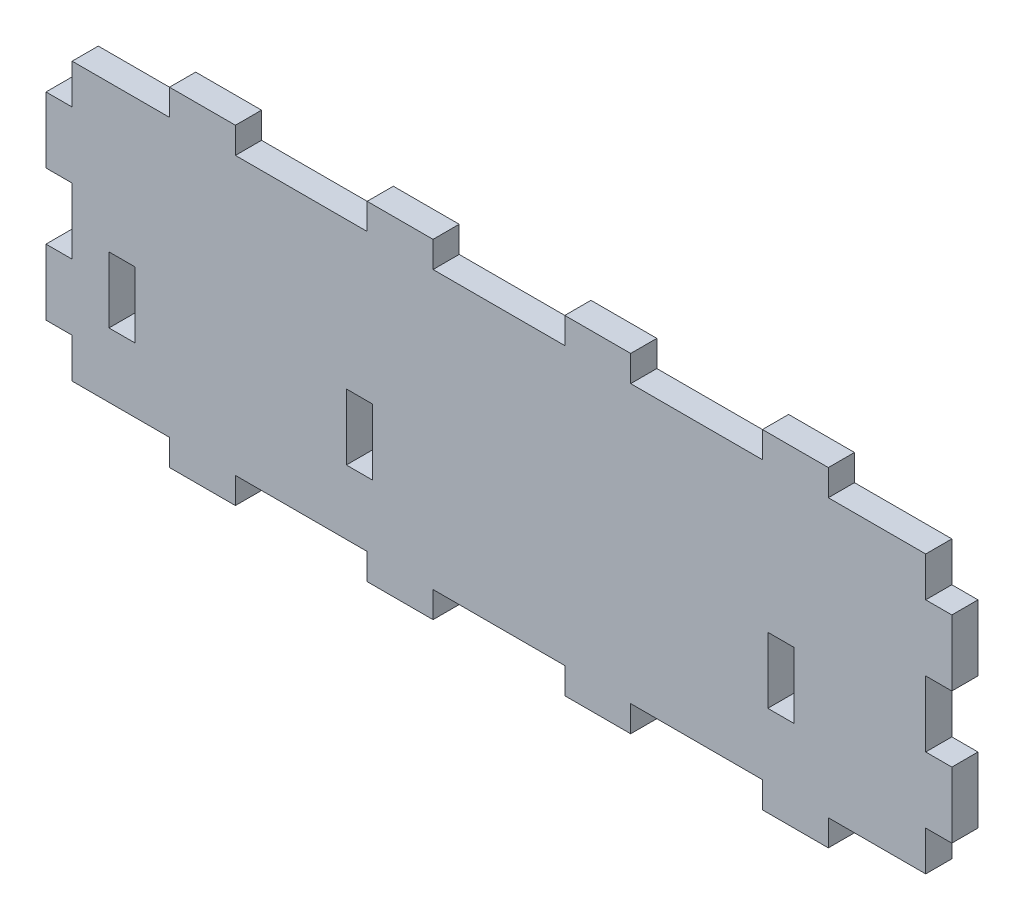
from build123d import *

# Parameters (mm, degrees)
SKETCH1_W           = 110
SKETCH1_H           = 40
BOSS_EXTRUDE1_DEPTH = 3.175
CUT_EXTRUDE5_REACH  = 5.175
SKETCH6_W           = 15
SKETCH6_H           = 3.175
SKETCH6_W_2         = 16
CUT_EXTRUDE6_REACH  = 5.175
SKETCH7_W           = 3.175
SKETCH7_H           = 4.825
SKETCH7_H_2         = 8
CUT_EXTRUDE7_REACH  = 5.175
SKETCH8_W           = 3.175
SKETCH8_H           = 8


with BuildPart() as part:
    # Sketch1 → Boss-Extrude1 (new body)
    with BuildSketch(Plane.XY):
        with Locations((55, -20)):
            Rectangle(SKETCH1_W, SKETCH1_H)
    extrude(amount=BOSS_EXTRUDE1_DEPTH)

    # Sketch6 → Cut-Extrude5 (cut, up to next)
    with BuildSketch(Plane(origin=(0, 0, 0), x_dir=(-1, 0, 0), z_dir=(0, 0, -1)), mode=Mode.PRIVATE) as cut_extrude5_sk1:
        with Locations((-102.5, -38.4125)):
            Rectangle(SKETCH6_W, SKETCH6_H)
    cut_extrude5_tool1 = extrude(cut_extrude5_sk1.sketch, amount=-CUT_EXTRUDE5_REACH, mode=Mode.PRIVATE) & part.part
    add(cut_extrude5_tool1.solids().sort_by_distance((102.5, -38.4125, 0))[0], mode=Mode.SUBTRACT)
    # Sketch6 → Cut-Extrude5 (cut, up to next)
    with BuildSketch(Plane(origin=(0, 0, 0), x_dir=(-1, 0, 0), z_dir=(0, 0, -1)), mode=Mode.PRIVATE) as cut_extrude5_sk2:
        with Locations((-55, -38.4125)):
            Rectangle(SKETCH6_W_2, SKETCH6_H)
    cut_extrude5_tool2 = extrude(cut_extrude5_sk2.sketch, amount=-CUT_EXTRUDE5_REACH, mode=Mode.PRIVATE) & part.part
    add(cut_extrude5_tool2.solids().sort_by_distance((55, -38.4125, 0))[0], mode=Mode.SUBTRACT)
    # Sketch6 → Cut-Extrude5 (cut, up to next)
    with BuildSketch(Plane(origin=(0, 0, 0), x_dir=(-1, 0, 0), z_dir=(0, 0, -1)), mode=Mode.PRIVATE) as cut_extrude5_sk3:
        with Locations((-31, -38.4125)):
            Rectangle(SKETCH6_W_2, SKETCH6_H)
    cut_extrude5_tool3 = extrude(cut_extrude5_sk3.sketch, amount=-CUT_EXTRUDE5_REACH, mode=Mode.PRIVATE) & part.part
    add(cut_extrude5_tool3.solids().sort_by_distance((31, -38.4125, 0))[0], mode=Mode.SUBTRACT)
    # Sketch6 → Cut-Extrude5 (cut, up to next)
    with BuildSketch(Plane(origin=(0, 0, 0), x_dir=(-1, 0, 0), z_dir=(0, 0, -1)), mode=Mode.PRIVATE) as cut_extrude5_sk4:
        with Locations((-7.5, -38.4125)):
            Rectangle(SKETCH6_W, SKETCH6_H)
    cut_extrude5_tool4 = extrude(cut_extrude5_sk4.sketch, amount=-CUT_EXTRUDE5_REACH, mode=Mode.PRIVATE) & part.part
    add(cut_extrude5_tool4.solids().sort_by_distance((7.5, -38.4125, 0))[0], mode=Mode.SUBTRACT)
    # Sketch6 → Cut-Extrude5 (cut, up to next)
    with BuildSketch(Plane(origin=(0, 0, 0), x_dir=(-1, 0, 0), z_dir=(0, 0, -1)), mode=Mode.PRIVATE) as cut_extrude5_sk5:
        with Locations((-79, -38.4125)):
            Rectangle(SKETCH6_W_2, SKETCH6_H)
    cut_extrude5_tool5 = extrude(cut_extrude5_sk5.sketch, amount=-CUT_EXTRUDE5_REACH, mode=Mode.PRIVATE) & part.part
    add(cut_extrude5_tool5.solids().sort_by_distance((79, -38.4125, 0))[0], mode=Mode.SUBTRACT)
    # Sketch6 → Cut-Extrude5 (cut, up to next)
    with BuildSketch(Plane(origin=(0, 0, 0), x_dir=(-1, 0, 0), z_dir=(0, 0, -1)), mode=Mode.PRIVATE) as cut_extrude5_sk6:
        with Locations((-55, -1.5875)):
            Rectangle(SKETCH6_W_2, SKETCH6_H)
    cut_extrude5_tool6 = extrude(cut_extrude5_sk6.sketch, amount=-CUT_EXTRUDE5_REACH, mode=Mode.PRIVATE) & part.part
    add(cut_extrude5_tool6.solids().sort_by_distance((55, -1.5875, 0))[0], mode=Mode.SUBTRACT)
    # Sketch6 → Cut-Extrude5 (cut, up to next)
    with BuildSketch(Plane(origin=(0, 0, 0), x_dir=(-1, 0, 0), z_dir=(0, 0, -1)), mode=Mode.PRIVATE) as cut_extrude5_sk7:
        with Locations((-79, -1.5875)):
            Rectangle(SKETCH6_W_2, SKETCH6_H)
    cut_extrude5_tool7 = extrude(cut_extrude5_sk7.sketch, amount=-CUT_EXTRUDE5_REACH, mode=Mode.PRIVATE) & part.part
    add(cut_extrude5_tool7.solids().sort_by_distance((79, -1.5875, 0))[0], mode=Mode.SUBTRACT)
    # Sketch6 → Cut-Extrude5 (cut, up to next)
    with BuildSketch(Plane(origin=(0, 0, 0), x_dir=(-1, 0, 0), z_dir=(0, 0, -1)), mode=Mode.PRIVATE) as cut_extrude5_sk8:
        with Locations((-102.5, -1.5875)):
            Rectangle(SKETCH6_W, SKETCH6_H)
    cut_extrude5_tool8 = extrude(cut_extrude5_sk8.sketch, amount=-CUT_EXTRUDE5_REACH, mode=Mode.PRIVATE) & part.part
    add(cut_extrude5_tool8.solids().sort_by_distance((102.5, -1.5875, 0))[0], mode=Mode.SUBTRACT)
    # Sketch6 → Cut-Extrude5 (cut, up to next)
    with BuildSketch(Plane(origin=(0, 0, 0), x_dir=(-1, 0, 0), z_dir=(0, 0, -1)), mode=Mode.PRIVATE) as cut_extrude5_sk9:
        with Locations((-7.5, -1.5875)):
            Rectangle(SKETCH6_W, SKETCH6_H)
    cut_extrude5_tool9 = extrude(cut_extrude5_sk9.sketch, amount=-CUT_EXTRUDE5_REACH, mode=Mode.PRIVATE) & part.part
    add(cut_extrude5_tool9.solids().sort_by_distance((7.5, -1.5875, 0))[0], mode=Mode.SUBTRACT)
    # Sketch6 → Cut-Extrude5 (cut, up to next)
    with BuildSketch(Plane(origin=(0, 0, 0), x_dir=(-1, 0, 0), z_dir=(0, 0, -1)), mode=Mode.PRIVATE) as cut_extrude5_sk10:
        with Locations((-31, -1.5875)):
            Rectangle(SKETCH6_W_2, SKETCH6_H)
    cut_extrude5_tool10 = extrude(cut_extrude5_sk10.sketch, amount=-CUT_EXTRUDE5_REACH, mode=Mode.PRIVATE) & part.part
    add(cut_extrude5_tool10.solids().sort_by_distance((31, -1.5875, 0))[0], mode=Mode.SUBTRACT)

    # Sketch7 → Cut-Extrude6 (cut, up to next)
    with BuildSketch(Plane(origin=(0, 0, 0), x_dir=(-1, 0, 0), z_dir=(0, 0, -1)), mode=Mode.PRIVATE) as cut_extrude6_sk1:
        with Locations((-108.4125, -34.4125)):
            Rectangle(SKETCH7_W, SKETCH7_H)
    cut_extrude6_tool1 = extrude(cut_extrude6_sk1.sketch, amount=-CUT_EXTRUDE6_REACH, mode=Mode.PRIVATE) & part.part
    add(cut_extrude6_tool1.solids().sort_by_distance((108.4125, -34.4125, 0))[0], mode=Mode.SUBTRACT)
    # Sketch7 → Cut-Extrude6 (cut, up to next)
    with BuildSketch(Plane(origin=(0, 0, 0), x_dir=(-1, 0, 0), z_dir=(0, 0, -1)), mode=Mode.PRIVATE) as cut_extrude6_sk2:
        with Locations((-108.4125, -20)):
            Rectangle(SKETCH7_W, SKETCH7_H_2)
    cut_extrude6_tool2 = extrude(cut_extrude6_sk2.sketch, amount=-CUT_EXTRUDE6_REACH, mode=Mode.PRIVATE) & part.part
    add(cut_extrude6_tool2.solids().sort_by_distance((108.4125, -20, 0))[0], mode=Mode.SUBTRACT)
    # Sketch7 → Cut-Extrude6 (cut, up to next)
    with BuildSketch(Plane(origin=(0, 0, 0), x_dir=(-1, 0, 0), z_dir=(0, 0, -1)), mode=Mode.PRIVATE) as cut_extrude6_sk3:
        with Locations((-108.4125, -5.5875)):
            Rectangle(SKETCH7_W, SKETCH7_H)
    cut_extrude6_tool3 = extrude(cut_extrude6_sk3.sketch, amount=-CUT_EXTRUDE6_REACH, mode=Mode.PRIVATE) & part.part
    add(cut_extrude6_tool3.solids().sort_by_distance((108.4125, -5.5875, 0))[0], mode=Mode.SUBTRACT)
    # Sketch7 → Cut-Extrude6 (cut, up to next)
    with BuildSketch(Plane(origin=(0, 0, 0), x_dir=(-1, 0, 0), z_dir=(0, 0, -1)), mode=Mode.PRIVATE) as cut_extrude6_sk4:
        with Locations((-1.5875, -20)):
            Rectangle(SKETCH7_W, SKETCH7_H_2)
    cut_extrude6_tool4 = extrude(cut_extrude6_sk4.sketch, amount=-CUT_EXTRUDE6_REACH, mode=Mode.PRIVATE) & part.part
    add(cut_extrude6_tool4.solids().sort_by_distance((1.5875, -20, 0))[0], mode=Mode.SUBTRACT)
    # Sketch7 → Cut-Extrude6 (cut, up to next)
    with BuildSketch(Plane(origin=(0, 0, 0), x_dir=(-1, 0, 0), z_dir=(0, 0, -1)), mode=Mode.PRIVATE) as cut_extrude6_sk5:
        with Locations((-1.5875, -34.4125)):
            Rectangle(SKETCH7_W, SKETCH7_H)
    cut_extrude6_tool5 = extrude(cut_extrude6_sk5.sketch, amount=-CUT_EXTRUDE6_REACH, mode=Mode.PRIVATE) & part.part
    add(cut_extrude6_tool5.solids().sort_by_distance((1.5875, -34.4125, 0))[0], mode=Mode.SUBTRACT)
    # Sketch7 → Cut-Extrude6 (cut, up to next)
    with BuildSketch(Plane(origin=(0, 0, 0), x_dir=(-1, 0, 0), z_dir=(0, 0, -1)), mode=Mode.PRIVATE) as cut_extrude6_sk6:
        with Locations((-1.5875, -5.5875)):
            Rectangle(SKETCH7_W, SKETCH7_H)
    cut_extrude6_tool6 = extrude(cut_extrude6_sk6.sketch, amount=-CUT_EXTRUDE6_REACH, mode=Mode.PRIVATE) & part.part
    add(cut_extrude6_tool6.solids().sort_by_distance((1.5875, -5.5875, 0))[0], mode=Mode.SUBTRACT)

    # Sketch8 → Cut-Extrude7 (cut, up to next)
    with BuildSketch(Plane(origin=(0, 0, 0), x_dir=(-1, 0, 0), z_dir=(0, 0, -1)), mode=Mode.PRIVATE) as cut_extrude7_sk1:
        with Locations((-38.0625, -24.995)):
            Rectangle(SKETCH8_W, SKETCH8_H)
    cut_extrude7_tool1 = extrude(cut_extrude7_sk1.sketch, amount=-CUT_EXTRUDE7_REACH, mode=Mode.PRIVATE) & part.part
    add(cut_extrude7_tool1.solids().sort_by_distance((38.0625, -24.995, 0))[0], mode=Mode.SUBTRACT)
    # Sketch8 → Cut-Extrude7 (cut, up to next)
    with BuildSketch(Plane(origin=(0, 0, 0), x_dir=(-1, 0, 0), z_dir=(0, 0, -1)), mode=Mode.PRIVATE) as cut_extrude7_sk2:
        with Locations((-89.2375, -24.995)):
            Rectangle(SKETCH8_W, SKETCH8_H)
    cut_extrude7_tool2 = extrude(cut_extrude7_sk2.sketch, amount=-CUT_EXTRUDE7_REACH, mode=Mode.PRIVATE) & part.part
    add(cut_extrude7_tool2.solids().sort_by_distance((89.2375, -24.995, 0))[0], mode=Mode.SUBTRACT)
    # Sketch8 → Cut-Extrude7 (cut, up to next)
    with BuildSketch(Plane(origin=(0, 0, 0), x_dir=(-1, 0, 0), z_dir=(0, 0, -1)), mode=Mode.PRIVATE) as cut_extrude7_sk3:
        with Locations((-9.2375, -24.995)):
            Rectangle(SKETCH8_W, SKETCH8_H)
    cut_extrude7_tool3 = extrude(cut_extrude7_sk3.sketch, amount=-CUT_EXTRUDE7_REACH, mode=Mode.PRIVATE) & part.part
    add(cut_extrude7_tool3.solids().sort_by_distance((9.2375, -24.995, 0))[0], mode=Mode.SUBTRACT)


solid = part.part
